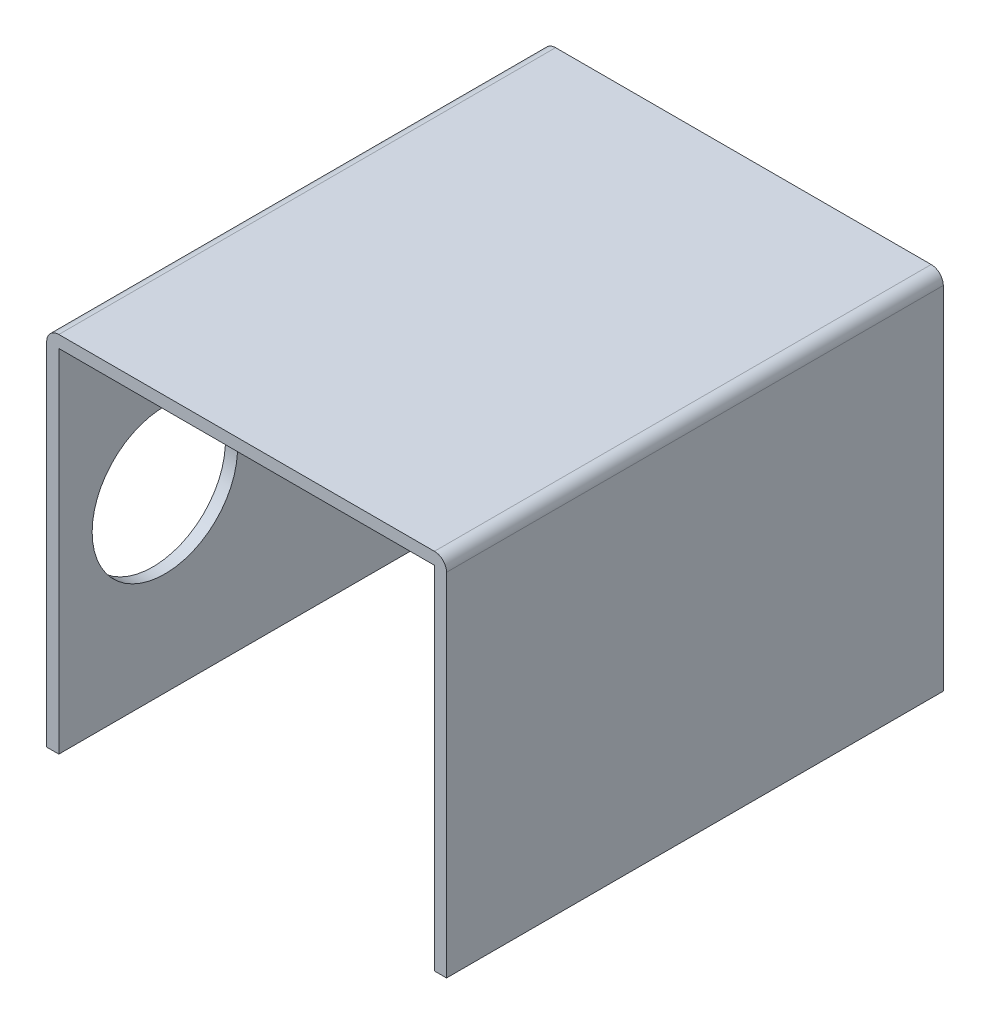
from build123d import *

# Parameters (mm, degrees)
EKSTR_ZYON_NCE1_DEPTH = 41
IZIM2_R               = 3
KES_EKSTR_ZYON1_DEPTH = 5
IZIM4_R               = 6
KES_EKSTR_ZYON3_DEPTH = 22


with BuildPart() as part:
    # Çizim1 → Ekstrüzyon-İnce1 (new body)
    with BuildSketch(Plane.XY):
        with BuildLine():
            Line((0, 0), (0, 29))
            ThreePointArc((0, 29), (0.292893219, 29.707106781), (1, 30))
            Line((1, 30), (32, 30))
            ThreePointArc((32, 30), (32.707106781, 29.707106781), (33, 29))
            Line((33, 29), (33, 0))
            Line((33, 0), (32, 0))
            Line((32, 0), (32, 29))
            Line((32, 29), (1, 29))
            Line((1, 29), (1, 0))
            Line((1, 0), (0, 0))
        make_face()
    extrude(amount=EKSTR_ZYON_NCE1_DEPTH)

    # Çizim2 → Kes-Ekstrüzyon1 (cut)
    with BuildSketch(Plane(origin=(0, 0, 0), x_dir=(0, 0, -1), z_dir=(1, 0, 0))):
        with Locations((-32.25, 14.5)):
            Circle(IZIM2_R)
        with Locations((-8.75, 14.5)):
            Circle(IZIM2_R)
    extrude(amount=KES_EKSTR_ZYON1_DEPTH, mode=Mode.SUBTRACT)

    # Çizim4 → Kes-Ekstrüzyon3 (cut)
    with BuildSketch(Plane.ZY):
        with Locations((32.25, 14.5)):
            Circle(IZIM4_R)
    extrude(amount=-KES_EKSTR_ZYON3_DEPTH, mode=Mode.SUBTRACT)


solid = part.part
